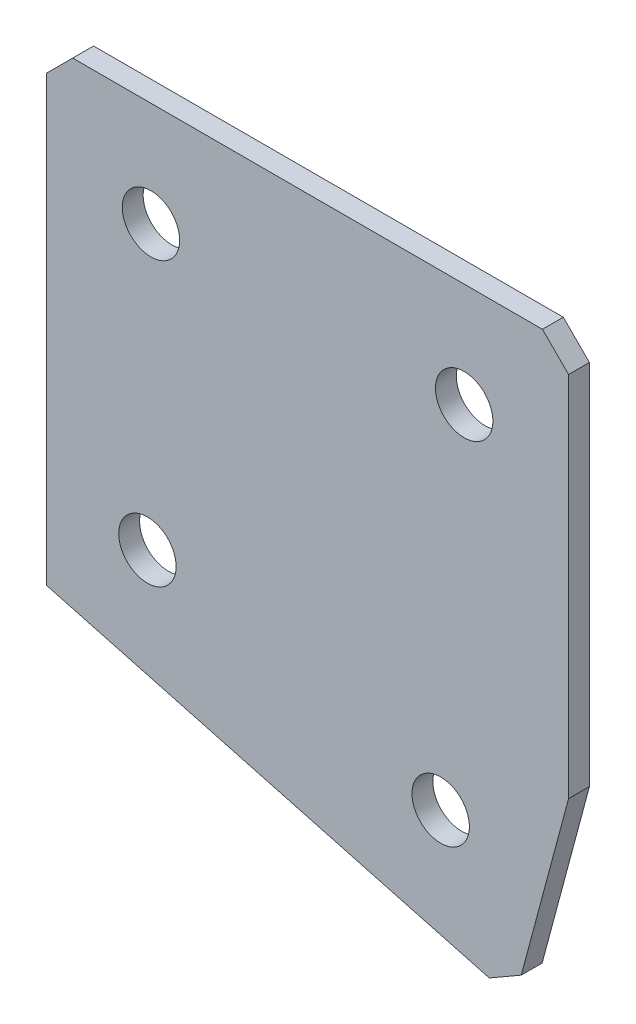
from build123d import *

# Parameters (mm, degrees)
EXTRUDE_1_DEPTH   = 2
HOLE_WIZARD_M51_D = 5.5
CHAMFER_1_SIZE    = 2.5


with BuildPart() as part:
    # Эскиз3 → Бобышка-Вытянуть1 (new body)
    with BuildSketch(Plane(origin=(0, 0, 0), x_dir=(1, 0, 0), z_dir=(0, 0, -1))):
        Polygon((0, 0), (50, 0), (50, 37.691936013), (44.823619098, 57.010452539), (0, 45), align=None)
    extrude(amount=EXTRUDE_1_DEPTH)

    # Отверстие с зазором M51 (through all)
    with Locations(Plane(origin=(0, 0, -2), x_dir=(1, 0, 0), z_dir=(0, 0, -1))):
        with Locations((10, 10), (40, 10), (9.659258263, 37.235428647), (37.752551286, 44.763003825)):
            Hole(HOLE_WIZARD_M51_D / 2)

    # Фаска1
    chamfer_1_edges = [part.edges().sort_by_distance(p)[0] for p in [
        (44.823619098, -57.010452539, -1),
        (50, 0, -1),
        (0, 0, -1),
    ]]
    chamfer(chamfer_1_edges, length=CHAMFER_1_SIZE)


solid = part.part
